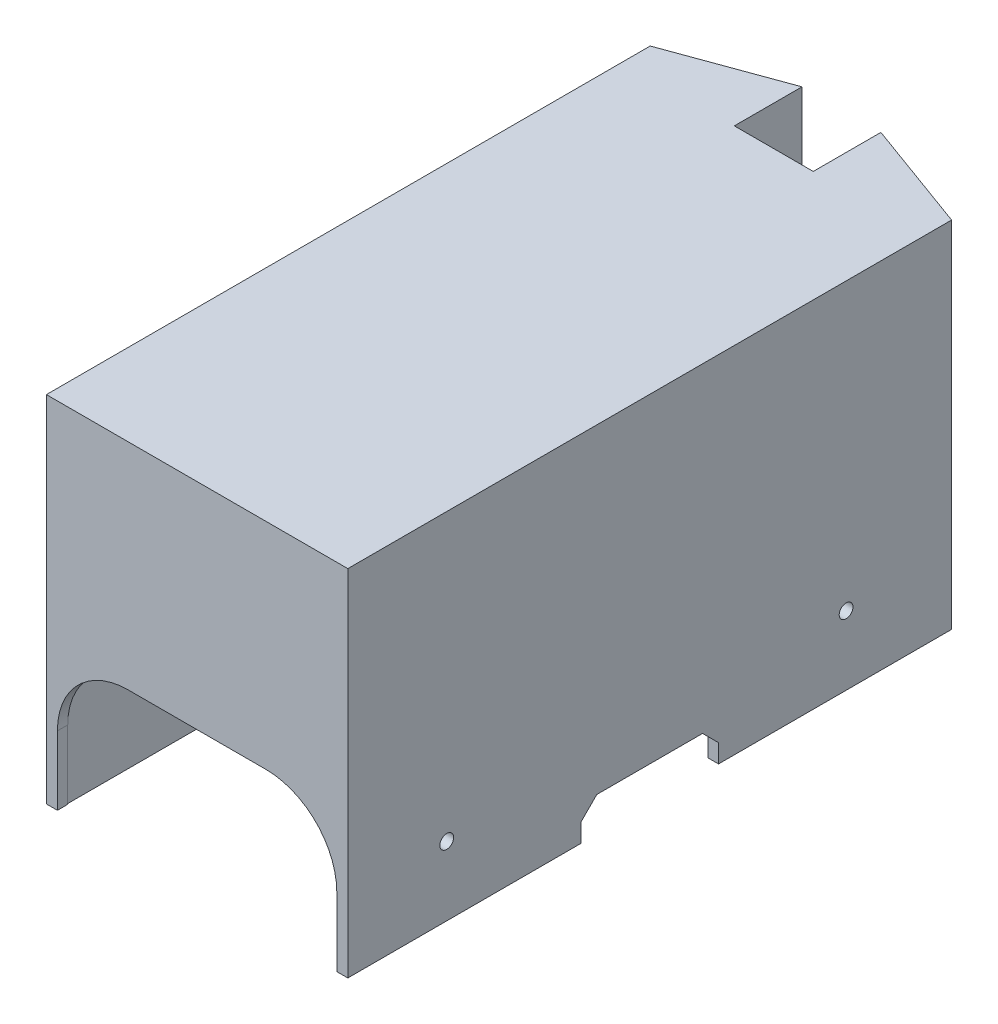
from build123d import *

# Parameters (mm, degrees)
BOSS_EXTRUDE1_DEPTH = 50
BOSS_EXTRUDE2_DEPTH = 1.52
CUT_EXTRUDE2_DEPTH  = 1.52
SKETCH4_R           = 1
CUT_EXTRUDE8_DEPTH  = 178.52
CUT_EXTRUDE9_DEPTH  = 178.52


with BuildPart() as part:
    # Sketch1 → Boss-Extrude1 (new body)
    with BuildSketch(Plane(origin=(0, 0, 0), x_dir=(1, 0, 0), z_dir=(0, 1, 0))):
        Polygon((-22.935245878, -45.076760645), (20.864754122, -45.076760645), (20.864754122, 42.660744493), (4.698193973, 48.553690828), (4.698193973, 38.723239355), (-6.768685729, 38.723239355), (-6.768685729, 48.553690828), (-22.935245878, 42.660744493), align=None)
        Polygon((-21.435245878, -43.576760645), (19.364754122, -43.576760645), (19.364754122, 41.610970221), (6.198193973, 46.410372917), (6.198193973, 37.223239355), (-8.268685729, 37.223239355), (-8.268685729, 46.410372917), (-21.435245878, 41.610970221), align=None, mode=Mode.SUBTRACT)
    extrude(amount=BOSS_EXTRUDE1_DEPTH)

    # Sketch2 → Boss-Extrude2 (add)
    with BuildSketch(Plane(origin=(0, 50, 0), x_dir=(1, 0, 0), z_dir=(0, 1, 0))):
        Polygon((-22.935245878, 42.660744493), (-22.935245878, -45.076760645), (20.864754122, -45.076760645), (20.864754122, 42.660744493), (4.698193973, 48.553690828), (4.698193973, 38.723239355), (-6.768685729, 38.723239355), (-6.768685729, 48.553690828), align=None)
    extrude(amount=BOSS_EXTRUDE2_DEPTH)

    # Sketch3 → Cut-Extrude2 (cut)
    with BuildSketch(Plane.XY.offset(45.076760645)):
        with BuildLine():
            Line((8.964754122, 20.3), (-11.035245878, 20.3))
            ThreePointArc((-11.035245878, 20.3), (-18.318445724, 17.283199846), (-21.335245878, 10))
            Line((-21.335245878, 10), (-21.335245878, -0.3))
            Line((-21.335245878, -0.3), (19.264754122, -0.3))
            Line((19.264754122, -0.3), (19.264754122, 10))
            ThreePointArc((19.264754122, 10), (16.247953968, 17.283199846), (8.964754122, 20.3))
        make_face()
    extrude(amount=-CUT_EXTRUDE2_DEPTH, mode=Mode.SUBTRACT)

    # Sketch4 → Cut-Extrude8 (cut)
    with BuildSketch(Plane(origin=(20.864754122, 0, 0), x_dir=(0, 0, -1), z_dir=(1, 0, 0))):
        with Locations((-30.703568725, 10)):
            Circle(SKETCH4_R)
        with Locations((27.32955957, 10)):
            Circle(SKETCH4_R)
    extrude(amount=-CUT_EXTRUDE8_DEPTH, mode=Mode.SUBTRACT)

    # Sketch5 → Cut-Extrude9 (cut)
    with BuildSketch(Plane(origin=(20.864754122, 0, 0), x_dir=(0, 0, -1), z_dir=(1, 0, 0))):
        Polygon((-11.208008076, 2.683848394), (-11.208008076, 0), (8.791991924, 0), (8.791991924, 2.683848394), (6.475840318, 5), (-8.89185647, 5), align=None)
    extrude(amount=-CUT_EXTRUDE9_DEPTH, mode=Mode.SUBTRACT)


solid = part.part
